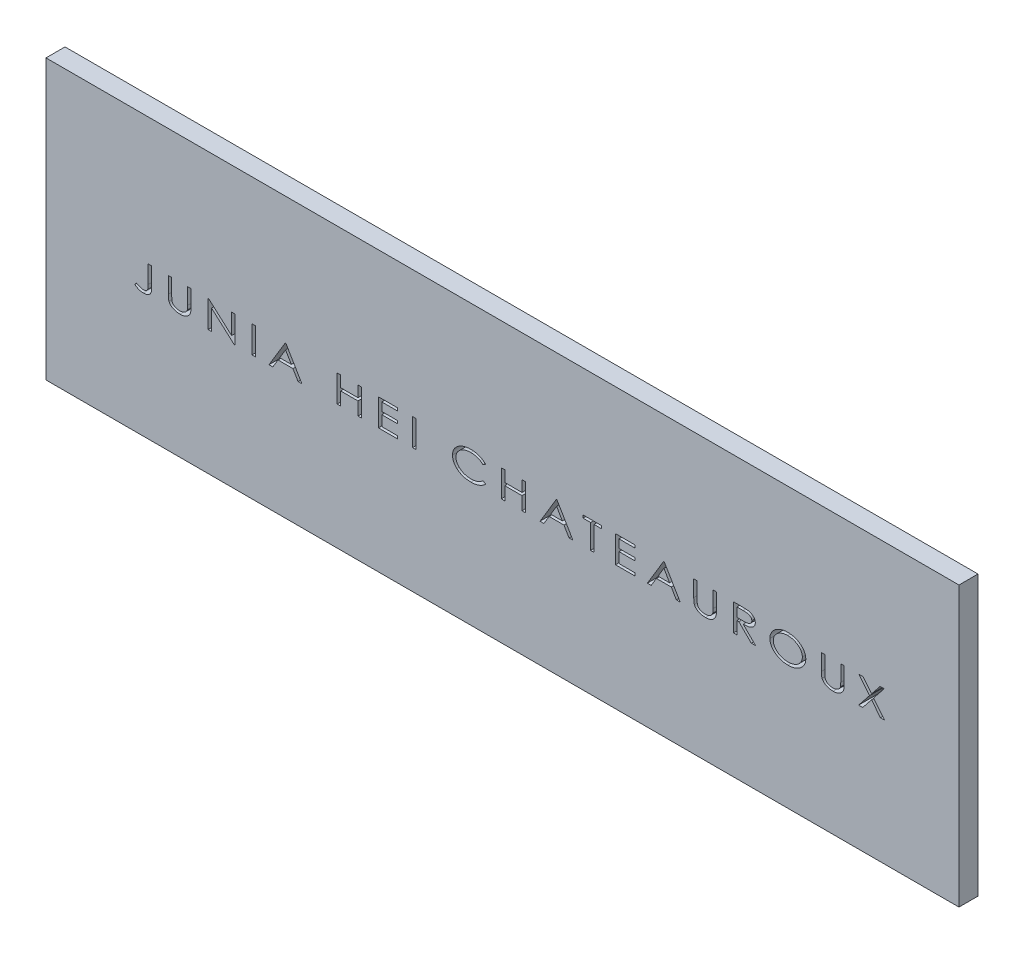
from build123d import *

# Parameters (mm, degrees)
SKETCH1_W           = 288
SKETCH1_H           = 88
BOSS_EXTRUDE2_DEPTH = 6
SKETCH4_W           = 1.089743589
SKETCH4_H           = 8.5
CUT_EXTRUDE1_DEPTH  = 6


with BuildPart() as part:
    # Sketch1 → Boss-Extrude2 (new body)
    with BuildSketch(Plane.XY):
        with Locations((144, 244)):
            Rectangle(SKETCH1_W, SKETCH1_H)
    extrude(amount=BOSS_EXTRUDE2_DEPTH)

    # Sketch4 → Cut-Extrude1 (cut)
    with BuildSketch(Plane(origin=(0, 0, 0), x_dir=(-1, 0, 0), z_dir=(0, 0, -1))):
        with BuildLine():
            Line((-32.232661343, 247.846298665), (-33.322404933, 247.846298665))
            Line((-33.322404933, 247.846298665), (-33.322404933, 242.106414851))
            add(Edge.make_bspline(
                [(-33.322404933, 242.106414851), (-33.322143071, 242.000258453), (-33.321640106, 241.79636091), (-33.306986401, 241.502834152), (-33.287138496, 241.234788221), (-33.261085681, 240.991332222), (-33.224090487, 240.773503018), (-33.177826903, 240.580349081), (-33.127097717, 240.411399805), (-33.064083482, 240.265502963), (-32.99033413, 240.137145921), (-32.907998112, 240.016825027), (-32.814973455, 239.90302313), (-32.70949607, 239.79725027), (-32.595590231, 239.695816939), (-32.468324397, 239.602514549), (-32.331291604, 239.513859194), (-32.130590183, 239.406213645), (-31.856870012, 239.292932833), (-31.498891197, 239.196026547), (-31.108504554, 239.137778787), (-30.837203035, 239.131565392), (-30.696803971, 239.128349947)],
                knots=[0, 0, 0, 0, 0.000318428, 0.000611613, 0.000881418, 0.001124735, 0.001345879, 0.001543704, 0.001720344, 0.001874391, 0.002019273, 0.002163794, 0.002311392, 0.00245949, 0.0026115, 0.002768493, 0.002932389, 0.00310076, 0.003451129, 0.003818353, 0.004210867, 0.004631857, 0.004631857, 0.004631857, 0.004631857], degree=3))
            add(Edge.make_bspline(
                [(-30.696803971, 239.128349947), (-30.587125113, 239.130903927), (-30.36814429, 239.13600311), (-30.041493838, 239.179372608), (-29.716518449, 239.244788248), (-29.390461597, 239.341799182), (-29.057450043, 239.47320037), (-28.712095096, 239.646125718), (-28.349871906, 239.859395541), (-28.108299793, 240.023678034), (-27.982661343, 240.109119178)],
                knots=[0, 0, 0, 0, 0.000328908, 0.000656686, 0.000986948, 0.001322593, 0.00167578, 0.002059569, 0.00248009, 0.002935813, 0.002935813, 0.002935813, 0.002935813], degree=3))
            Line((-27.982661343, 240.109119178), (-28.554776727, 240.762965332))
            add(Edge.make_bspline(
                [(-28.554776727, 240.762965332), (-28.69037213, 240.6913204), (-28.947444111, 240.555490541), (-29.321735951, 240.382122734), (-29.655603756, 240.23291275), (-29.871038788, 240.157764296), (-29.971443394, 240.122740973)],
                knots=[0, 0, 0, 0, 0.000459975, 0.000872056, 0.001237384, 0.001556262, 0.001556262, 0.001556262, 0.001556262], degree=3))
            add(Edge.make_bspline(
                [(-29.971443394, 240.122740973), (-30.032510773, 240.104297733), (-30.153591639, 240.067729545), (-30.336739424, 240.028434551), (-30.518598911, 240.006034686), (-30.638854315, 240.002097734), (-30.698506695, 240.000144819)],
                knots=[0, 0, 0, 0, 0.00019132, 0.000379338, 0.000561179, 0.000740168, 0.000740168, 0.000740168, 0.000740168], degree=3))
            add(Edge.make_bspline(
                [(-30.698506695, 240.000144819), (-30.774766252, 240.002627901), (-30.925008446, 240.007519927), (-31.143945233, 240.050238862), (-31.353156648, 240.115973541), (-31.546938816, 240.211939268), (-31.724018445, 240.326432864), (-31.872352033, 240.465289104), (-31.994165309, 240.620059308), (-32.071259249, 240.767112622), (-32.119112554, 240.901480205), (-32.148109188, 241.024471556), (-32.175515914, 241.16752242), (-32.197682752, 241.331748736), (-32.211536674, 241.517136026), (-32.223346636, 241.723194328), (-32.232774314, 241.95024878), (-32.232700144, 242.108674348), (-32.232661343, 242.191551069)],
                knots=[0, 0, 0, 0, 0.000228571, 0.000450318, 0.000666785, 0.000884581, 0.001097094, 0.00129709, 0.001491231, 0.001685446, 0.00179208, 0.001918449, 0.00206405, 0.002229003, 0.002415232, 0.002621606, 0.002848228, 0.003096832, 0.003096832, 0.003096832, 0.003096832], degree=3))
            Line((-32.232661343, 242.191551069), (-32.232661343, 247.846298665))
        make_face()
        with BuildLine():
            Line((-38.574969035, 247.846298665), (-39.664712625, 247.846298665))
            Line((-39.664712625, 247.846298665), (-39.664712625, 242.753450107))
            add(Edge.make_bspline(
                [(-39.664712625, 242.753450107), (-39.664341426, 242.681364336), (-39.663636974, 242.544561694), (-39.668342681, 242.349910297), (-39.670554593, 242.176748616), (-39.676805088, 242.024702092), (-39.679988742, 241.893966708), (-39.689905194, 241.784582209), (-39.69673009, 241.696300344), (-39.705297023, 241.644941394), (-39.708983458, 241.622841133)],
                knots=[0, 0, 0, 0, 0.000216246, 0.000410386, 0.000584098, 0.000735726, 0.000866935, 0.000976242, 0.001065192, 0.001132379, 0.001132379, 0.001132379, 0.001132379], degree=3))
            add(Edge.make_bspline(
                [(-39.708983458, 241.622841133), (-39.725140639, 241.542869518), (-39.756744487, 241.386443043), (-39.837031437, 241.165132359), (-39.946076341, 240.964746635), (-40.082046954, 240.782294765), (-40.254653261, 240.618816089), (-40.463726682, 240.471376447), (-40.712740638, 240.338912931), (-40.99310461, 240.220937502), (-41.294683106, 240.124164303), (-41.60318656, 240.052229319), (-41.912708888, 240.007746719), (-42.119331158, 240.002671619), (-42.222204612, 240.000144819)],
                knots=[0, 0, 0, 0, 0.000244529, 0.000478305, 0.000703071, 0.00092681, 0.001158029, 0.001413171, 0.001692023, 0.002002578, 0.002324586, 0.002640968, 0.002952087, 0.003260581, 0.003260581, 0.003260581, 0.003260581], degree=3))
            add(Edge.make_bspline(
                [(-42.222204612, 240.000144819), (-42.310820451, 240.002775051), (-42.48749071, 240.00801885), (-42.749446337, 240.039693565), (-43.005072235, 240.098031044), (-43.253998306, 240.172120623), (-43.48854256, 240.271293439), (-43.707413867, 240.385036149), (-43.904802591, 240.517836032), (-44.082029738, 240.667153536), (-44.239000651, 240.832958871), (-44.370670285, 241.017904454), (-44.484880941, 241.217247749), (-44.539245085, 241.36088626), (-44.566856054, 241.433838729)],
                knots=[0, 0, 0, 0, 0.000265892, 0.0005301, 0.000789954, 0.00105172, 0.001308176, 0.00155267, 0.001790686, 0.002020257, 0.002246726, 0.002473566, 0.002699977, 0.002933647, 0.002933647, 0.002933647, 0.002933647], degree=3))
            add(Edge.make_bspline(
                [(-44.566856054, 241.433838729), (-44.575907062, 241.463788463), (-44.596011534, 241.530314051), (-44.616097029, 241.643510477), (-44.637301645, 241.776698538), (-44.651527084, 241.931425699), (-44.663435219, 242.106847357), (-44.671555708, 242.303869255), (-44.676676999, 242.52185168), (-44.677239388, 242.673986269), (-44.677533138, 242.753450107)],
                knots=[0, 0, 0, 0, 9.3789e-05, 0.000208328, 0.000344386, 0.000498396, 0.000674181, 0.00087188, 0.001089889, 0.001328276, 0.001328276, 0.001328276, 0.001328276], degree=3))
            Line((-44.677533138, 242.753450107), (-44.677533138, 247.846298665))
            Line((-44.677533138, 247.846298665), (-45.767276727, 247.846298665))
            Line((-45.767276727, 247.846298665), (-45.767276727, 242.712584723))
            add(Edge.make_bspline(
                [(-45.767276727, 242.712584723), (-45.766036417, 242.620059559), (-45.763615667, 242.439475578), (-45.752312855, 242.174747413), (-45.730895399, 241.923516219), (-45.697395534, 241.686378805), (-45.659806597, 241.462578086), (-45.609640504, 241.252517924), (-45.552517847, 241.0555944), (-45.486175329, 240.87043853), (-45.404935418, 240.695934361), (-45.307432065, 240.528030422), (-45.191336391, 240.366408633), (-45.05672218, 240.210527303), (-44.906272312, 240.059180382), (-44.7351479, 239.915844299), (-44.548530738, 239.776512243), (-44.345100216, 239.643805081), (-44.126552455, 239.523721083), (-43.896022232, 239.41807872), (-43.655113503, 239.327087461), (-43.402285012, 239.253930948), (-43.137484481, 239.198374856), (-42.861783186, 239.157347831), (-42.575088361, 239.133539049), (-42.380601358, 239.130098023), (-42.281799965, 239.128349947)],
                knots=[0, 0, 0, 0, 0.000277591, 0.000541782, 0.000794756, 0.001033635, 0.001260104, 0.001475282, 0.001681107, 0.001875023, 0.002064707, 0.002257747, 0.002456674, 0.002660753, 0.002875066, 0.003096139, 0.003329753, 0.003573451, 0.003824174, 0.004077125, 0.00433361, 0.004596034, 0.004865871, 0.005144723, 0.005431772, 0.005728169, 0.005728169, 0.005728169, 0.005728169], degree=3))
            add(Edge.make_bspline(
                [(-42.281799965, 239.128349947), (-42.17393248, 239.130251199), (-41.9625119, 239.13397766), (-41.650838381, 239.155417183), (-41.351590038, 239.195626009), (-41.062766485, 239.24673485), (-40.786990542, 239.317926355), (-40.521635946, 239.399963483), (-40.269830552, 239.501612107), (-40.029747335, 239.614653632), (-39.806019838, 239.74158267), (-39.600592393, 239.880018694), (-39.413963403, 240.028235918), (-39.247125284, 240.187172125), (-39.096613748, 240.354052315), (-38.969973631, 240.534137748), (-38.858246231, 240.721498131), (-38.802196873, 240.854736549), (-38.774187785, 240.921318697)],
                knots=[0, 0, 0, 0, 0.00032363, 0.000634315, 0.000936543, 0.001229104, 0.001513643, 0.001790439, 0.002061728, 0.002327539, 0.002586045, 0.002832564, 0.003070031, 0.003300075, 0.00352321, 0.003742921, 0.003959616, 0.004176069, 0.004176069, 0.004176069, 0.004176069], degree=3))
            add(Edge.make_bspline(
                [(-38.774187785, 240.921318697), (-38.758144392, 240.966500865), (-38.723482692, 241.064116793), (-38.683813293, 241.2266162), (-38.650892796, 241.413887854), (-38.621654122, 241.625679804), (-38.600304613, 241.862050394), (-38.585147802, 242.12326788), (-38.57721097, 242.409450728), (-38.575737246, 242.608714242), (-38.574969035, 242.712584723)],
                knots=[0, 0, 0, 0, 0.000143767, 0.000310608, 0.000500978, 0.000714091, 0.000951802, 0.00121277, 0.001498954, 0.001810571, 0.001810571, 0.001810571, 0.001810571], degree=3))
            Line((-38.574969035, 242.712584723), (-38.574969035, 247.846298665))
        make_face()
        Polygon((-51.128815189, 239.346298665), (-51.128815189, 247.846298665), (-51.358682977, 247.846298665), (-58.539071599, 241.416811486), (-58.539071599, 247.846298665), (-59.628815189, 247.846298665), (-59.628815189, 239.346298665), (-59.380217433, 239.346298665), (-52.218558779, 245.760461325), (-52.218558779, 239.346298665), align=None)
        with Locations((-65.535225446, 243.596298665)):
            Rectangle(SKETCH4_W, SKETCH4_H)
        Polygon((-75.691635702, 247.846298665), (-80.704456215, 239.346298665), (-79.504035542, 239.346298665), (-77.896663747, 242.070657639), (-73.200549965, 242.070657639), (-71.557420958, 239.346298665), (-70.351892112, 239.346298665), (-75.473686984, 247.846298665), align=None)
        Polygon((-75.574147721, 246.010761806), (-73.724989067, 242.942452511), (-77.384143715, 242.942452511), align=None, mode=Mode.SUBTRACT)
        Polygon((-91.863430574, 247.846298665), (-92.953174163, 247.846298665), (-92.953174163, 244.359119178), (-98.401892112, 244.359119178), (-98.401892112, 247.846298665), (-99.491635702, 247.846298665), (-99.491635702, 239.346298665), (-98.401892112, 239.346298665), (-98.401892112, 243.487324306), (-92.953174163, 243.487324306), (-92.953174163, 239.346298665), (-91.863430574, 239.346298665), align=None)
        Polygon((-104.853174163, 247.846298665), (-110.955738266, 247.846298665), (-110.955738266, 246.974503793), (-105.942917753, 246.974503793), (-105.942917753, 244.359119178), (-110.955738266, 244.359119178), (-110.955738266, 243.487324306), (-105.942917753, 243.487324306), (-105.942917753, 240.218093537), (-110.955738266, 240.218093537), (-110.955738266, 239.346298665), (-104.853174163, 239.346298665), align=None)
        with Locations((-116.208302369, 243.596298665)):
            Rectangle(SKETCH4_W, SKETCH4_H)
        with BuildLine():
            Line((-138.700610061, 246.286603152), (-137.849247881, 245.775785845))
            add(Edge.make_bspline(
                [(-137.849247881, 245.775785845), (-137.789634588, 245.832575671), (-137.670817467, 245.945765255), (-137.482568125, 246.104992598), (-137.28485207, 246.25272136), (-137.079033019, 246.391084977), (-136.863323801, 246.51749672), (-136.638917839, 246.63245447), (-136.406332145, 246.739069316), (-136.164979811, 246.833516667), (-135.916913677, 246.918814688), (-135.662388048, 246.992439306), (-135.401825866, 247.052832938), (-135.135113146, 247.105064002), (-134.862133655, 247.142915432), (-134.58338869, 247.172602839), (-134.298723518, 247.189911217), (-134.106682683, 247.191599215), (-134.009604452, 247.192452511)],
                knots=[0, 0, 0, 0, 0.000246965, 0.000492235, 0.00073913, 0.000987062, 0.001235869, 0.0014887, 0.001743198, 0.002003108, 0.00226588, 0.002529939, 0.002797571, 0.003068063, 0.003344985, 0.003624034, 0.003908898, 0.004200109, 0.004200109, 0.004200109, 0.004200109], degree=3))
            add(Edge.make_bspline(
                [(-134.009604452, 247.192452511), (-133.903414396, 247.191491937), (-133.693025909, 247.189588805), (-133.38062486, 247.163783789), (-133.073646658, 247.127246445), (-132.772321743, 247.074596781), (-132.477662072, 247.00581591), (-132.188273033, 246.924946215), (-131.906026376, 246.824812193), (-131.629607573, 246.714197003), (-131.365053588, 246.588268152), (-131.113960107, 246.451620404), (-130.877225829, 246.306127148), (-130.656781679, 246.148758456), (-130.451941137, 245.981642344), (-130.261699967, 245.804298638), (-130.088693639, 245.614927337), (-129.929697123, 245.417614226), (-129.788151558, 245.211744738), (-129.665782973, 244.99853648), (-129.559940064, 244.779637774), (-129.477943875, 244.552439541), (-129.410708182, 244.320599417), (-129.362328112, 244.082120444), (-129.33556266, 243.83699874), (-129.3310758, 243.671279309), (-129.328815189, 243.587785043)],
                knots=[0, 0, 0, 0, 0.000318482, 0.000630991, 0.000939762, 0.001245732, 0.001548075, 0.001847217, 0.002146625, 0.002446058, 0.002740053, 0.003025019, 0.003303335, 0.003573124, 0.003836931, 0.00409593, 0.004352613, 0.004605769, 0.004855612, 0.005101235, 0.005342668, 0.005584011, 0.005824915, 0.006066348, 0.006313049, 0.006563558, 0.006563558, 0.006563558, 0.006563558], degree=3))
            add(Edge.make_bspline(
                [(-129.328815189, 243.587785043), (-129.332447006, 243.462069773), (-129.339594033, 243.214675538), (-129.405060515, 242.85211282), (-129.510130011, 242.505669757), (-129.66109707, 242.176117433), (-129.850427085, 241.860814256), (-130.084982855, 241.563009435), (-130.360628552, 241.281705012), (-130.674824244, 241.019500475), (-131.020493341, 240.781257286), (-131.390613207, 240.570362961), (-131.785312671, 240.395006444), (-132.200580575, 240.250696371), (-132.637854865, 240.137392334), (-133.096988402, 240.059218724), (-133.578200193, 240.007495619), (-133.906733814, 240.002627756), (-134.074307977, 240.000144819)],
                knots=[0, 0, 0, 0, 0.000376856, 0.000741613, 0.0011014, 0.00146032, 0.001826215, 0.002202251, 0.002594788, 0.003005741, 0.003427992, 0.003852712, 0.004281815, 0.004721768, 0.00517027, 0.005635242, 0.006117942, 0.00662048, 0.00662048, 0.00662048, 0.00662048], degree=3))
            add(Edge.make_bspline(
                [(-134.074307977, 240.000144819), (-134.167422638, 240.000922451), (-134.3515429, 240.002460101), (-134.625248856, 240.020914808), (-134.893032683, 240.046709729), (-135.155240592, 240.087202386), (-135.411831688, 240.135349623), (-135.662145847, 240.197337011), (-135.907239524, 240.268808082), (-136.146270875, 240.35230494), (-136.380355356, 240.445413487), (-136.606973494, 240.552054989), (-136.829134371, 240.667484202), (-137.044762175, 240.795338858), (-137.255350348, 240.933526551), (-137.459080184, 241.08404235), (-137.65943464, 241.243104071), (-137.785770841, 241.35872053), (-137.849247881, 241.416811486)],
                knots=[0, 0, 0, 0, 0.000279294, 0.000552261, 0.000822667, 0.001086111, 0.001347921, 0.001605619, 0.001859393, 0.002113561, 0.002364931, 0.002614791, 0.002864599, 0.003115737, 0.003366507, 0.003619887, 0.003875437, 0.0041335, 0.0041335, 0.0041335, 0.0041335], degree=3))
            Line((-137.849247881, 241.416811486), (-138.700610061, 240.911102351))
            add(Edge.make_bspline(
                [(-138.700610061, 240.911102351), (-138.632748743, 240.841582184), (-138.496352736, 240.701852019), (-138.276814147, 240.507482761), (-138.045942799, 240.323765531), (-137.801334354, 240.153663156), (-137.545371252, 239.993911409), (-137.276441254, 239.846749606), (-136.995396403, 239.712638993), (-136.70286575, 239.590159545), (-136.399663253, 239.480667677), (-136.086566877, 239.388107564), (-135.765134158, 239.307464551), (-135.435087405, 239.241078489), (-135.095833446, 239.1899316), (-134.748019913, 239.155091643), (-134.391904676, 239.131667758), (-134.15153639, 239.129463922), (-134.030037144, 239.128349947)],
                knots=[0, 0, 0, 0, 0.00029137, 0.000585631, 0.000878945, 0.001176064, 0.001478924, 0.001783731, 0.002095222, 0.002412715, 0.002734796, 0.003061794, 0.003391758, 0.003728696, 0.004071367, 0.004420558, 0.004777115, 0.005141562, 0.005141562, 0.005141562, 0.005141562], degree=3))
            add(Edge.make_bspline(
                [(-134.030037144, 239.128349947), (-133.914786521, 239.128978955), (-133.686962911, 239.130222357), (-133.349726406, 239.150729584), (-133.021287457, 239.178270413), (-132.702303042, 239.220256625), (-132.392194738, 239.269591466), (-132.092193404, 239.335814733), (-131.80088198, 239.409588074), (-131.519161931, 239.496987234), (-131.24677047, 239.595313454), (-130.983691201, 239.706325976), (-130.730155934, 239.82941877), (-130.484400089, 239.961476759), (-130.248884242, 240.10707313), (-130.022328645, 240.263439136), (-129.80507951, 240.432256071), (-129.668142056, 240.553896894), (-129.599548362, 240.614828312)],
                knots=[0, 0, 0, 0, 0.000345691, 0.00068335, 0.001013248, 0.001334269, 0.001648347, 0.001954932, 0.002255582, 0.002549646, 0.00283943, 0.00312405, 0.003405823, 0.003684675, 0.003960648, 0.004236011, 0.004510197, 0.004785386, 0.004785386, 0.004785386, 0.004785386], degree=3))
            add(Edge.make_bspline(
                [(-129.599548362, 240.614828312), (-129.491260511, 240.720072966), (-129.278204019, 240.927141964), (-129.000586567, 241.267548316), (-128.764627852, 241.623712858), (-128.573787468, 241.997170029), (-128.421292171, 242.385571986), (-128.317640083, 242.791767002), (-128.249312133, 243.213141322), (-128.242518119, 243.500104693), (-128.239071599, 243.645677671)],
                knots=[0, 0, 0, 0, 0.000452713, 0.000890714, 0.001314802, 0.001732119, 0.002146665, 0.002563791, 0.002987629, 0.003424005, 0.003424005, 0.003424005, 0.003424005], degree=3))
            add(Edge.make_bspline(
                [(-128.239071599, 243.645677671), (-128.240522649, 243.722899737), (-128.243396969, 243.875865534), (-128.262017214, 244.102840055), (-128.29507934, 244.324948953), (-128.338634881, 244.542987293), (-128.396652119, 244.756325364), (-128.468697466, 244.964115228), (-128.552158964, 245.167978666), (-128.649560862, 245.366623788), (-128.758267952, 245.561700079), (-128.882112168, 245.750541923), (-129.016013753, 245.936863356), (-129.164833947, 246.116825735), (-129.32500285, 246.293077806), (-129.499692621, 246.463374431), (-129.686592276, 246.62987695), (-129.952759444, 246.84588494), (-130.306856263, 247.09528272), (-130.759946567, 247.355402505), (-131.23957846, 247.573056022), (-131.743563813, 247.754981519), (-132.274803384, 247.894125535), (-132.831825646, 247.99165036), (-133.414558099, 248.052810374), (-133.811934305, 248.060383082), (-134.014712625, 248.064247383)],
                knots=[0, 0, 0, 0, 0.000231671, 0.000458906, 0.000682612, 0.000905012, 0.001125585, 0.001345283, 0.001564412, 0.001786015, 0.002008623, 0.002233904, 0.002463122, 0.002696619, 0.002934056, 0.003177277, 0.003428127, 0.003684748, 0.004205336, 0.004725515, 0.005249733, 0.005783479, 0.006331124, 0.006894929, 0.007478608, 0.008086824, 0.008086824, 0.008086824, 0.008086824], degree=3))
            add(Edge.make_bspline(
                [(-134.014712625, 248.064247383), (-134.138477353, 248.063094948), (-134.382806222, 248.06081988), (-134.744716996, 248.038054098), (-135.096888168, 248.000684136), (-135.439955123, 247.949302001), (-135.774567745, 247.885747018), (-136.099233787, 247.803267136), (-136.415111956, 247.707769299), (-136.721204371, 247.599567662), (-137.015726787, 247.476376782), (-137.298317278, 247.343034695), (-137.565774005, 247.19546741), (-137.821274765, 247.039579022), (-138.060661015, 246.867788628), (-138.290227119, 246.688551073), (-138.503080814, 246.493865746), (-138.634973198, 246.355474302), (-138.700610061, 246.286603152)],
                knots=[0, 0, 0, 0, 0.000371256, 0.000732912, 0.001087361, 0.0014334, 0.001773348, 0.002108681, 0.0024378, 0.002763088, 0.003082152, 0.00339518, 0.003699987, 0.003998158, 0.004292493, 0.004583415, 0.004871478, 0.00515685, 0.00515685, 0.00515685, 0.00515685], degree=3))
        make_face()
        Polygon((-143.626251086, 247.846298665), (-144.715994676, 247.846298665), (-144.715994676, 244.359119178), (-150.164712625, 244.359119178), (-150.164712625, 247.846298665), (-151.254456215, 247.846298665), (-151.254456215, 239.346298665), (-150.164712625, 239.346298665), (-150.164712625, 243.487324306), (-144.715994676, 243.487324306), (-144.715994676, 239.346298665), (-143.626251086, 239.346298665), align=None)
        Polygon((-161.192917753, 247.846298665), (-166.205738266, 239.346298665), (-165.005317593, 239.346298665), (-163.397945798, 242.070657639), (-158.701832016, 242.070657639), (-157.05870301, 239.346298665), (-155.853174163, 239.346298665), (-160.974969035, 247.846298665), align=None)
        Polygon((-161.075429772, 246.010761806), (-159.226271118, 242.942452511), (-162.885425766, 242.942452511), align=None, mode=Mode.SUBTRACT)
        Polygon((-169.387789548, 246.974503793), (-169.387789548, 247.846298665), (-175.272404933, 247.846298665), (-175.272404933, 246.974503793), (-172.874969035, 246.974503793), (-172.874969035, 239.346298665), (-171.785225445, 239.346298665), (-171.785225445, 246.974503793), align=None)
        Polygon((-179.653174163, 247.846298665), (-185.755738266, 247.846298665), (-185.755738266, 246.974503793), (-180.742917753, 246.974503793), (-180.742917753, 244.359119178), (-185.755738266, 244.359119178), (-185.755738266, 243.487324306), (-180.742917753, 243.487324306), (-180.742917753, 240.218093537), (-185.755738266, 240.218093537), (-185.755738266, 239.346298665), (-179.653174163, 239.346298665), align=None)
        Polygon((-195.040353651, 247.846298665), (-200.053174163, 239.346298665), (-198.85275349, 239.346298665), (-197.245381695, 242.070657639), (-192.549267913, 242.070657639), (-190.906138907, 239.346298665), (-189.700610061, 239.346298665), (-194.822404933, 247.846298665), align=None)
        Polygon((-194.92286567, 246.010761806), (-193.073707016, 242.942452511), (-196.732861663, 242.942452511), align=None, mode=Mode.SUBTRACT)
        with BuildLine():
            Line((-204.324969035, 247.846298665), (-205.414712625, 247.846298665))
            Line((-205.414712625, 247.846298665), (-205.414712625, 242.753450107))
            add(Edge.make_bspline(
                [(-205.414712625, 242.753450107), (-205.414341426, 242.681364336), (-205.413636974, 242.544561694), (-205.418342681, 242.349910297), (-205.420554593, 242.176748616), (-205.426805088, 242.024702092), (-205.429988742, 241.893966708), (-205.439905194, 241.784582209), (-205.44673009, 241.696300344), (-205.455297023, 241.644941394), (-205.458983458, 241.622841133)],
                knots=[0, 0, 0, 0, 0.000216246, 0.000410386, 0.000584098, 0.000735726, 0.000866935, 0.000976242, 0.001065192, 0.001132379, 0.001132379, 0.001132379, 0.001132379], degree=3))
            add(Edge.make_bspline(
                [(-205.458983458, 241.622841133), (-205.475140639, 241.542869518), (-205.506744487, 241.386443043), (-205.587031437, 241.165132359), (-205.696076341, 240.964746635), (-205.832046954, 240.782294765), (-206.004653261, 240.618816089), (-206.213726682, 240.471376447), (-206.462740638, 240.338912931), (-206.74310461, 240.220937502), (-207.044683106, 240.124164303), (-207.35318656, 240.052229319), (-207.662708888, 240.007746719), (-207.869331158, 240.002671619), (-207.972204612, 240.000144819)],
                knots=[0, 0, 0, 0, 0.000244529, 0.000478305, 0.000703071, 0.00092681, 0.001158029, 0.001413171, 0.001692023, 0.002002578, 0.002324586, 0.002640968, 0.002952087, 0.003260581, 0.003260581, 0.003260581, 0.003260581], degree=3))
            add(Edge.make_bspline(
                [(-207.972204612, 240.000144819), (-208.060820451, 240.002775051), (-208.23749071, 240.00801885), (-208.499446337, 240.039693565), (-208.755072235, 240.098031044), (-209.003998306, 240.172120623), (-209.23854256, 240.271293439), (-209.457413867, 240.385036149), (-209.654802591, 240.517836032), (-209.832029738, 240.667153536), (-209.989000651, 240.832958871), (-210.120670285, 241.017904454), (-210.234880941, 241.217247749), (-210.289245085, 241.36088626), (-210.316856054, 241.433838729)],
                knots=[0, 0, 0, 0, 0.000265892, 0.0005301, 0.000789954, 0.00105172, 0.001308176, 0.00155267, 0.001790686, 0.002020257, 0.002246726, 0.002473566, 0.002699977, 0.002933647, 0.002933647, 0.002933647, 0.002933647], degree=3))
            add(Edge.make_bspline(
                [(-210.316856054, 241.433838729), (-210.325907062, 241.463788463), (-210.346011534, 241.530314051), (-210.366097029, 241.643510477), (-210.387301645, 241.776698538), (-210.401527084, 241.931425699), (-210.413435219, 242.106847357), (-210.421555708, 242.303869255), (-210.426676999, 242.52185168), (-210.427239388, 242.673986269), (-210.427533138, 242.753450107)],
                knots=[0, 0, 0, 0, 9.3789e-05, 0.000208328, 0.000344386, 0.000498396, 0.000674181, 0.00087188, 0.001089889, 0.001328276, 0.001328276, 0.001328276, 0.001328276], degree=3))
            Line((-210.427533138, 242.753450107), (-210.427533138, 247.846298665))
            Line((-210.427533138, 247.846298665), (-211.517276727, 247.846298665))
            Line((-211.517276727, 247.846298665), (-211.517276727, 242.712584723))
            add(Edge.make_bspline(
                [(-211.517276727, 242.712584723), (-211.516036417, 242.620059559), (-211.513615667, 242.439475578), (-211.502312855, 242.174747413), (-211.480895399, 241.923516219), (-211.447395534, 241.686378805), (-211.409806597, 241.462578086), (-211.359640504, 241.252517924), (-211.302517847, 241.0555944), (-211.236175329, 240.87043853), (-211.154935418, 240.695934361), (-211.057432065, 240.528030422), (-210.941336391, 240.366408633), (-210.80672218, 240.210527303), (-210.656272312, 240.059180382), (-210.4851479, 239.915844299), (-210.298530738, 239.776512243), (-210.095100216, 239.643805081), (-209.876552455, 239.523721083), (-209.646022232, 239.41807872), (-209.405113503, 239.327087461), (-209.152285012, 239.253930948), (-208.887484481, 239.198374856), (-208.611783186, 239.157347831), (-208.325088361, 239.133539049), (-208.130601358, 239.130098023), (-208.031799965, 239.128349947)],
                knots=[0, 0, 0, 0, 0.000277591, 0.000541782, 0.000794756, 0.001033635, 0.001260104, 0.001475282, 0.001681107, 0.001875023, 0.002064707, 0.002257747, 0.002456674, 0.002660753, 0.002875066, 0.003096139, 0.003329753, 0.003573451, 0.003824174, 0.004077125, 0.00433361, 0.004596034, 0.004865871, 0.005144723, 0.005431772, 0.005728169, 0.005728169, 0.005728169, 0.005728169], degree=3))
            add(Edge.make_bspline(
                [(-208.031799965, 239.128349947), (-207.92393248, 239.130251199), (-207.7125119, 239.13397766), (-207.400838381, 239.155417183), (-207.101590038, 239.195626009), (-206.812766485, 239.24673485), (-206.536990542, 239.317926355), (-206.271635946, 239.399963483), (-206.019830552, 239.501612107), (-205.779747335, 239.614653632), (-205.556019838, 239.74158267), (-205.350592393, 239.880018694), (-205.163963403, 240.028235918), (-204.997125284, 240.187172125), (-204.846613748, 240.354052315), (-204.719973631, 240.534137748), (-204.608246231, 240.721498131), (-204.552196873, 240.854736549), (-204.524187785, 240.921318697)],
                knots=[0, 0, 0, 0, 0.00032363, 0.000634315, 0.000936543, 0.001229104, 0.001513643, 0.001790439, 0.002061728, 0.002327539, 0.002586045, 0.002832564, 0.003070031, 0.003300075, 0.00352321, 0.003742921, 0.003959616, 0.004176069, 0.004176069, 0.004176069, 0.004176069], degree=3))
            add(Edge.make_bspline(
                [(-204.524187785, 240.921318697), (-204.508144392, 240.966500865), (-204.473482692, 241.064116793), (-204.433813293, 241.2266162), (-204.400892796, 241.413887854), (-204.371654122, 241.625679804), (-204.350304613, 241.862050394), (-204.335147802, 242.12326788), (-204.32721097, 242.409450728), (-204.325737246, 242.608714242), (-204.324969035, 242.712584723)],
                knots=[0, 0, 0, 0, 0.000143767, 0.000310608, 0.000500978, 0.000714091, 0.000951802, 0.00121277, 0.001498954, 0.001810571, 0.001810571, 0.001810571, 0.001810571], degree=3))
            Line((-204.324969035, 242.712584723), (-204.324969035, 247.846298665))
        make_face()
        with BuildLine():
            Line((-216.878815189, 247.846298665), (-219.065113266, 247.846298665))
            add(Edge.make_bspline(
                [(-219.065113266, 247.846298665), (-219.211546993, 247.845925285), (-219.491937666, 247.845210339), (-219.893844643, 247.841123916), (-220.258745713, 247.829566112), (-220.586966045, 247.819592183), (-220.878056847, 247.801378628), (-221.132575224, 247.78408232), (-221.350201714, 247.761122889), (-221.482481318, 247.740075458), (-221.542577208, 247.730513409)],
                knots=[0, 0, 0, 0, 0.000439306, 0.000841182, 0.001205708, 0.00153455, 0.001826213, 0.002080609, 0.002299858, 0.002482391, 0.002482391, 0.002482391, 0.002482391], degree=3))
            add(Edge.make_bspline(
                [(-221.542577208, 247.730513409), (-221.622283562, 247.715144536), (-221.779489901, 247.68483222), (-222.006872978, 247.621418768), (-222.222889936, 247.546079994), (-222.428134359, 247.45942016), (-222.621874112, 247.359490963), (-222.803399152, 247.245823505), (-222.97469795, 247.121982741), (-223.131689791, 246.984368113), (-223.275800246, 246.837975634), (-223.402109389, 246.682548137), (-223.506307107, 246.516429664), (-223.594825973, 246.344582845), (-223.65980224, 246.162588861), (-223.711566012, 245.9740841), (-223.737343169, 245.77592777), (-223.741894744, 245.641327462), (-223.744199804, 245.573161646)],
                knots=[0, 0, 0, 0, 0.000243442, 0.000480145, 0.000707393, 0.000929408, 0.001147974, 0.00136059, 0.001571405, 0.0017814, 0.001986096, 0.002187132, 0.002380802, 0.002573458, 0.002765776, 0.002959475, 0.003158861, 0.003363443, 0.003363443, 0.003363443, 0.003363443], degree=3))
            add(Edge.make_bspline(
                [(-223.744199804, 245.573161646), (-223.742971873, 245.51576517), (-223.740544526, 245.402305054), (-223.718795733, 245.235075385), (-223.687564569, 245.072991114), (-223.640517095, 244.916530321), (-223.581627623, 244.765148233), (-223.507093776, 244.61919499), (-223.420630127, 244.478527039), (-223.321681018, 244.342912658), (-223.208576337, 244.216148589), (-223.08629586, 244.094209217), (-222.951128763, 243.982445909), (-222.805677402, 243.877060889), (-222.646710041, 243.783150836), (-222.478033191, 243.693553977), (-222.297310875, 243.614338385), (-222.104942647, 243.541651552), (-221.897062103, 243.47924478), (-221.671908343, 243.421941572), (-221.426913691, 243.378087419), (-221.164170664, 243.338127388), (-220.882930764, 243.308075567), (-220.582521444, 243.28617057), (-220.263388384, 243.272510813), (-220.044193478, 243.270438288), (-219.931799965, 243.269375588)],
                knots=[0, 0, 0, 0, 0.00017211, 0.000340223, 0.000505186, 0.00066681, 0.000829649, 0.000991847, 0.00115772, 0.001324596, 0.001494707, 0.001666884, 0.001842165, 0.00202031, 0.002205155, 0.002395564, 0.002592999, 0.002796672, 0.003012119, 0.003243796, 0.003493261, 0.003758389, 0.004041005, 0.004341501, 0.004661903, 0.004999081, 0.004999081, 0.004999081, 0.004999081], degree=3))
            Line((-219.931799965, 243.269375588), (-223.853174163, 239.346298665))
            Line((-223.853174163, 239.346298665), (-222.467156535, 239.346298665))
            Line((-222.467156535, 239.346298665), (-218.545782336, 243.269375588))
            Line((-218.545782336, 243.269375588), (-217.968558779, 243.269375588))
            Line((-217.968558779, 243.269375588), (-217.968558779, 239.346298665))
            Line((-217.968558779, 239.346298665), (-216.878815189, 239.346298665))
            Line((-216.878815189, 239.346298665), (-216.878815189, 247.846298665))
        make_face()
        with BuildLine():
            Line((-217.968558779, 246.974503793), (-217.968558779, 244.14117046))
            Line((-217.968558779, 244.14117046), (-219.880718234, 244.129251389))
            add(Edge.make_bspline(
                [(-219.880718234, 244.129251389), (-219.970406195, 244.129210173), (-220.143584601, 244.12913059), (-220.393883121, 244.138864337), (-220.62614856, 244.149847174), (-220.840793229, 244.166876006), (-221.037376556, 244.188366985), (-221.21577238, 244.215602561), (-221.376122428, 244.247556267), (-221.563217246, 244.296013776), (-221.772250265, 244.372839246), (-221.998803855, 244.48549866), (-222.193041181, 244.627254904), (-222.357988223, 244.789152), (-222.488916578, 244.968947502), (-222.58522628, 245.161278386), (-222.643773241, 245.36486523), (-222.65088594, 245.504682161), (-222.654456215, 245.57486437)],
                knots=[0, 0, 0, 0, 0.000269036, 0.000519481, 0.000751358, 0.000966576, 0.001165329, 0.001344495, 0.001507788, 0.001655641, 0.001923895, 0.002174432, 0.002412162, 0.002642131, 0.002865214, 0.003076146, 0.003284776, 0.003495047, 0.003495047, 0.003495047, 0.003495047], degree=3))
            add(Edge.make_bspline(
                [(-222.654456215, 245.57486437), (-222.650880737, 245.643354987), (-222.643755356, 245.779846295), (-222.584988474, 245.97912081), (-222.487597472, 246.167331258), (-222.353199959, 246.340957659), (-222.193122864, 246.501741375), (-222.003063935, 246.635886534), (-221.79131744, 246.748360385), (-221.594772458, 246.818653393), (-221.419134525, 246.86304347), (-221.265764137, 246.893629164), (-221.092375077, 246.918597707), (-220.898611842, 246.938435813), (-220.684620401, 246.955703), (-220.450101421, 246.967093187), (-220.195198078, 246.974033604), (-220.018643892, 246.974342773), (-219.926691792, 246.974503793)],
                knots=[0, 0, 0, 0, 0.000205184, 0.000408899, 0.000617558, 0.000837552, 0.001065113, 0.001295711, 0.001532592, 0.001782516, 0.001919625, 0.002075905, 0.00225145, 0.00244494, 0.002660158, 0.002895436, 0.003149233, 0.00342508, 0.00342508, 0.00342508, 0.00342508], degree=3))
            Line((-219.926691792, 246.974503793), (-217.968558779, 246.974503793))
        make_face(mode=Mode.SUBTRACT)
        with BuildLine():
            add(Edge.make_bspline(
                [(-233.939772721, 248.064247383), (-234.139124462, 248.060235184), (-234.530793725, 248.052352359), (-235.10611212, 247.992933357), (-235.655994503, 247.889345449), (-236.182845275, 247.751858245), (-236.683081703, 247.568154104), (-237.159251141, 247.346287224), (-237.610416581, 247.083419011), (-237.962903141, 246.830686728), (-238.228777462, 246.6128625), (-238.415661087, 246.444633811), (-238.590354395, 246.272631882), (-238.750513209, 246.0946743), (-238.899337556, 245.913005955), (-239.033226349, 245.72498467), (-239.157089844, 245.534440465), (-239.265716286, 245.337635407), (-239.363616931, 245.13692303), (-239.446231351, 244.930449555), (-239.518740903, 244.720577401), (-239.576651838, 244.505504832), (-239.620435619, 244.285240198), (-239.653157613, 244.060811148), (-239.671951025, 243.831596108), (-239.674808584, 243.677494789), (-239.676251086, 243.599704114)],
                knots=[0, 0, 0, 0, 0.000598005, 0.00117491, 0.001732624, 0.002275331, 0.002806456, 0.003329012, 0.003849422, 0.004370592, 0.004628289, 0.004880275, 0.005124692, 0.005363389, 0.005598205, 0.005828803, 0.006055515, 0.006279609, 0.006502744, 0.006725026, 0.006946334, 0.007168551, 0.00739262, 0.007619696, 0.007848628, 0.008082001, 0.008082001, 0.008082001, 0.008082001], degree=3))
            add(Edge.make_bspline(
                [(-239.676251086, 243.599704114), (-239.674808373, 243.52248092), (-239.671950565, 243.369512887), (-239.653162658, 243.141994581), (-239.620417721, 242.919274954), (-239.576718969, 242.700676161), (-239.518342924, 242.486903224), (-239.446801253, 242.277800285), (-239.362737044, 242.072799117), (-239.267975979, 241.871436245), (-239.158015969, 241.67509837), (-239.036167163, 241.48322492), (-238.899765658, 241.296454155), (-238.753068186, 241.113110096), (-238.590844819, 240.935338765), (-238.418717524, 240.760281184), (-238.231449076, 240.591302632), (-237.967135205, 240.371912276), (-237.616408799, 240.119199165), (-237.170686271, 239.853026925), (-236.702366903, 239.628022493), (-236.210071275, 239.445699917), (-235.697179323, 239.301805729), (-235.160271764, 239.202791151), (-234.601948442, 239.139529725), (-234.221463982, 239.132114315), (-234.028314388, 239.128349947)],
                knots=[0, 0, 0, 0, 0.000231671, 0.000458906, 0.000684297, 0.000906697, 0.00112727, 0.001348578, 0.001569283, 0.001791683, 0.002015777, 0.002243923, 0.00247314, 0.002709279, 0.002947977, 0.003194801, 0.003445524, 0.003704305, 0.004225085, 0.004740493, 0.005259891, 0.005781431, 0.006313535, 0.006855873, 0.00741772, 0.007997007, 0.007997007, 0.007997007, 0.007997007], degree=3))
            add(Edge.make_bspline(
                [(-234.028314388, 239.128349947), (-233.83289588, 239.132095665), (-233.448449985, 239.139464598), (-232.883903891, 239.202877863), (-232.342095194, 239.301851401), (-231.82371128, 239.443816518), (-231.328359637, 239.626012627), (-230.856272929, 239.849691565), (-230.408692282, 240.115478567), (-230.056140899, 240.366860004), (-229.790513579, 240.584969475), (-229.602796953, 240.75293278), (-229.430020742, 240.926790625), (-229.267937249, 241.102948791), (-229.120453475, 241.284606751), (-228.985888115, 241.470936351), (-228.862068818, 241.659829987), (-228.753901041, 241.854590551), (-228.655517582, 242.052197178), (-228.572972717, 242.255317076), (-228.500407046, 242.461762936), (-228.442760375, 242.672928609), (-228.398695587, 242.888593231), (-228.366020831, 243.107931985), (-228.347212819, 243.332046855), (-228.344358753, 243.482749792), (-228.342917753, 243.558838729)],
                knots=[0, 0, 0, 0, 0.000586093, 0.001153019, 0.001702052, 0.002236984, 0.002763313, 0.003283514, 0.00380185, 0.00432302, 0.004580717, 0.004832703, 0.005078321, 0.005315758, 0.005550573, 0.005779791, 0.006005072, 0.00622768, 0.006447753, 0.006666883, 0.006884971, 0.007103902, 0.007322965, 0.007544987, 0.007768828, 0.007997095, 0.007997095, 0.007997095, 0.007997095], degree=3))
            add(Edge.make_bspline(
                [(-228.342917753, 243.558838729), (-228.345140939, 243.659980404), (-228.349563822, 243.861195152), (-228.387230477, 244.159944592), (-228.444400486, 244.453926448), (-228.526406137, 244.742139797), (-228.632591675, 245.024497489), (-228.763002194, 245.300530669), (-228.914227485, 245.572176944), (-229.090385715, 245.835259514), (-229.284683612, 246.089613357), (-229.498671472, 246.330888662), (-229.730181267, 246.556779095), (-229.978253703, 246.768847905), (-230.242820862, 246.966650704), (-230.524491234, 247.150570278), (-230.822599871, 247.321399224), (-231.137290053, 247.474799521), (-231.462202557, 247.614923652), (-231.797279619, 247.733212106), (-232.137916349, 247.836191192), (-232.485893855, 247.919446739), (-232.840026872, 247.984292574), (-233.201033121, 248.029485516), (-233.568041187, 248.060326502), (-233.815410094, 248.062935654), (-233.939772721, 248.064247383)],
                knots=[0, 0, 0, 0, 0.000303319, 0.000603434, 0.000901969, 0.001201112, 0.001501241, 0.001805928, 0.002116189, 0.002433069, 0.002754902, 0.003075747, 0.003399646, 0.003724509, 0.004054157, 0.004389939, 0.004733134, 0.005084184, 0.005439675, 0.005794054, 0.006149594, 0.006506829, 0.006866858, 0.007229062, 0.007597988, 0.007970982, 0.007970982, 0.007970982, 0.007970982], degree=3))
        make_face()
        with BuildLine():
            add(Edge.make_bspline(
                [(-233.987449003, 247.192452511), (-233.888066325, 247.191487803), (-233.690707225, 247.189572036), (-233.396472642, 247.163598929), (-233.105941685, 247.127155244), (-232.819112973, 247.074886048), (-232.537313109, 247.003347285), (-232.258295483, 246.921125052), (-231.983362192, 246.821622571), (-231.714675433, 246.708252408), (-231.454406843, 246.583070819), (-231.20772426, 246.445295755), (-230.975388959, 246.296590995), (-230.757095124, 246.138608212), (-230.553932444, 245.96974289), (-230.365542617, 245.79004694), (-230.191855808, 245.599546774), (-230.034067887, 245.398976863), (-229.891962867, 245.191318949), (-229.769104088, 244.976038384), (-229.66457019, 244.754862466), (-229.581703624, 244.526946654), (-229.514313075, 244.294531129), (-229.466525587, 244.055956058), (-229.439281365, 243.810908155), (-229.434884285, 243.645743245), (-229.432661343, 243.562244178)],
                knots=[0, 0, 0, 0, 0.000298055, 0.000591892, 0.000885457, 0.001176344, 0.001465838, 0.001757282, 0.002048667, 0.002342455, 0.002631843, 0.002914649, 0.003189548, 0.00345895, 0.003722526, 0.003981458, 0.004239396, 0.004495219, 0.004746468, 0.004993568, 0.005238079, 0.005479422, 0.005720326, 0.005963428, 0.006208437, 0.006458946, 0.006458946, 0.006458946, 0.006458946], degree=3))
            add(Edge.make_bspline(
                [(-229.432661343, 243.562244178), (-229.436289972, 243.43935649), (-229.443445712, 243.197019121), (-229.509233223, 242.84204448), (-229.612867625, 242.501366188), (-229.761451611, 242.176062035), (-229.949623128, 241.863949716), (-230.181896814, 241.568575483), (-230.455139246, 241.287824681), (-230.766238031, 241.025707346), (-231.10590338, 240.785117074), (-231.467706932, 240.575869122), (-231.845691194, 240.397443082), (-232.241432237, 240.252838091), (-232.653417374, 240.137896626), (-233.083786432, 240.059438757), (-233.529849762, 240.007676464), (-233.833487055, 240.002678885), (-233.987449003, 240.000144819)],
                knots=[0, 0, 0, 0, 0.000368356, 0.000726406, 0.001079182, 0.001434297, 0.001796397, 0.002170044, 0.002558985, 0.002969733, 0.003388773, 0.003806107, 0.004221994, 0.004641106, 0.005068666, 0.005503478, 0.005952317, 0.006414009, 0.006414009, 0.006414009, 0.006414009], degree=3))
            add(Edge.make_bspline(
                [(-233.987449003, 240.000144819), (-234.091354469, 240.001316946), (-234.297703762, 240.003644711), (-234.604046111, 240.026441491), (-234.904716061, 240.063699214), (-235.199013802, 240.116655973), (-235.487547333, 240.183556617), (-235.770851304, 240.262252588), (-236.046782783, 240.360970422), (-236.31680777, 240.470239497), (-236.575779326, 240.594189982), (-236.822352983, 240.72879165), (-237.053700515, 240.875138539), (-237.270543571, 241.031893979), (-237.47269212, 241.199497928), (-237.659789618, 241.378209899), (-237.833025462, 241.567613659), (-237.988755112, 241.768921855), (-238.130583456, 241.976612515), (-238.250982511, 242.192866195), (-238.356884298, 242.412490915), (-238.438889193, 242.640188701), (-238.507081552, 242.871754363), (-238.551546018, 243.110293966), (-238.582668339, 243.353686382), (-238.585221679, 243.518439841), (-238.586507497, 243.601406838)],
                knots=[0, 0, 0, 0, 0.000311673, 0.000618962, 0.000920973, 0.001220237, 0.00151556, 0.001809323, 0.002101741, 0.002394223, 0.002682874, 0.002962541, 0.003236526, 0.00350355, 0.003764728, 0.00402366, 0.004279193, 0.004533965, 0.004786623, 0.005032884, 0.005275855, 0.005517197, 0.005758101, 0.005999204, 0.006244408, 0.006493151, 0.006493151, 0.006493151, 0.006493151], degree=3))
            add(Edge.make_bspline(
                [(-238.586507497, 243.601406838), (-238.585220738, 243.683806608), (-238.582665599, 243.847429272), (-238.551559288, 244.089127823), (-238.507033743, 244.325954123), (-238.439196629, 244.555376712), (-238.356820448, 244.780151767), (-238.250957242, 244.996370272), (-238.130524465, 245.209230158), (-237.988686871, 245.413483073), (-237.832560363, 245.612152438), (-237.657993877, 245.798484477), (-237.470336838, 245.977283279), (-237.265424642, 246.143007671), (-237.04674534, 246.301144434), (-236.811532014, 246.446373596), (-236.561954412, 246.583829298), (-236.297985827, 246.707769869), (-236.025168696, 246.822107791), (-235.745944979, 246.92073143), (-235.462628679, 247.003679003), (-235.176170235, 247.074858938), (-234.8848095, 247.126990381), (-234.589222324, 247.163839506), (-234.28985008, 247.189486152), (-234.088531147, 247.191460961), (-233.987449003, 247.192452511)],
                knots=[0, 0, 0, 0, 0.000247042, 0.000490555, 0.000729986, 0.000969254, 0.001207404, 0.001447301, 0.0016906, 0.001940443, 0.002192538, 0.002447969, 0.002705728, 0.002969535, 0.00323794, 0.003514809, 0.003798281, 0.004092276, 0.004389205, 0.0046854, 0.00498011, 0.005274563, 0.005570474, 0.005867418, 0.006168044, 0.006471206, 0.006471206, 0.006471206, 0.006471206], degree=3))
        make_face(mode=Mode.SUBTRACT)
        with BuildLine():
            Line((-244.601892112, 247.846298665), (-245.691635702, 247.846298665))
            Line((-245.691635702, 247.846298665), (-245.691635702, 242.753450107))
            add(Edge.make_bspline(
                [(-245.691635702, 242.753450107), (-245.691264503, 242.681364336), (-245.690560051, 242.544561694), (-245.695265758, 242.349910297), (-245.69747767, 242.176748616), (-245.703728165, 242.024702092), (-245.706911819, 241.893966708), (-245.716828271, 241.784582209), (-245.723653167, 241.696300344), (-245.7322201, 241.644941394), (-245.735906535, 241.622841133)],
                knots=[0, 0, 0, 0, 0.000216246, 0.000410386, 0.000584098, 0.000735726, 0.000866935, 0.000976242, 0.001065192, 0.001132379, 0.001132379, 0.001132379, 0.001132379], degree=3))
            add(Edge.make_bspline(
                [(-245.735906535, 241.622841133), (-245.752063716, 241.542869518), (-245.783667564, 241.386443043), (-245.863954514, 241.165132359), (-245.972999418, 240.964746635), (-246.108970031, 240.782294765), (-246.281576338, 240.618816089), (-246.490649759, 240.471376447), (-246.739663715, 240.338912931), (-247.020027686, 240.220937502), (-247.321606183, 240.124164303), (-247.630109637, 240.052229319), (-247.939631965, 240.007746719), (-248.146254235, 240.002671619), (-248.249127689, 240.000144819)],
                knots=[0, 0, 0, 0, 0.000244529, 0.000478305, 0.000703071, 0.00092681, 0.001158029, 0.001413171, 0.001692023, 0.002002578, 0.002324586, 0.002640968, 0.002952087, 0.003260581, 0.003260581, 0.003260581, 0.003260581], degree=3))
            add(Edge.make_bspline(
                [(-248.249127689, 240.000144819), (-248.337743528, 240.002775051), (-248.514413787, 240.00801885), (-248.776369414, 240.039693565), (-249.031995312, 240.098031044), (-249.280921383, 240.172120623), (-249.515465637, 240.271293439), (-249.734336944, 240.385036149), (-249.931725668, 240.517836032), (-250.108952815, 240.667153536), (-250.265923727, 240.832958871), (-250.397593362, 241.017904454), (-250.511804018, 241.217247749), (-250.566168162, 241.36088626), (-250.593779131, 241.433838729)],
                knots=[0, 0, 0, 0, 0.000265892, 0.0005301, 0.000789954, 0.00105172, 0.001308176, 0.00155267, 0.001790686, 0.002020257, 0.002246726, 0.002473566, 0.002699977, 0.002933647, 0.002933647, 0.002933647, 0.002933647], degree=3))
            add(Edge.make_bspline(
                [(-250.593779131, 241.433838729), (-250.602830139, 241.463788463), (-250.622934611, 241.530314051), (-250.643020106, 241.643510477), (-250.664224722, 241.776698538), (-250.678450161, 241.931425699), (-250.690358296, 242.106847357), (-250.698478785, 242.303869255), (-250.703600076, 242.52185168), (-250.704162465, 242.673986269), (-250.704456215, 242.753450107)],
                knots=[0, 0, 0, 0, 9.3789e-05, 0.000208328, 0.000344386, 0.000498396, 0.000674181, 0.00087188, 0.001089889, 0.001328276, 0.001328276, 0.001328276, 0.001328276], degree=3))
            Line((-250.704456215, 242.753450107), (-250.704456215, 247.846298665))
            Line((-250.704456215, 247.846298665), (-251.794199804, 247.846298665))
            Line((-251.794199804, 247.846298665), (-251.794199804, 242.712584723))
            add(Edge.make_bspline(
                [(-251.794199804, 242.712584723), (-251.792959494, 242.620059559), (-251.790538744, 242.439475578), (-251.779235932, 242.174747413), (-251.757818476, 241.923516219), (-251.724318611, 241.686378805), (-251.686729674, 241.462578086), (-251.636563581, 241.252517924), (-251.579440924, 241.0555944), (-251.513098406, 240.87043853), (-251.431858495, 240.695934361), (-251.334355142, 240.528030422), (-251.218259468, 240.366408633), (-251.083645257, 240.210527303), (-250.933195389, 240.059180382), (-250.762070977, 239.915844299), (-250.575453815, 239.776512243), (-250.372023293, 239.643805081), (-250.153475532, 239.523721083), (-249.922945309, 239.41807872), (-249.68203658, 239.327087461), (-249.429208089, 239.253930948), (-249.164407558, 239.198374856), (-248.888706263, 239.157347831), (-248.602011438, 239.133539049), (-248.407524435, 239.130098023), (-248.308723042, 239.128349947)],
                knots=[0, 0, 0, 0, 0.000277591, 0.000541782, 0.000794756, 0.001033635, 0.001260104, 0.001475282, 0.001681107, 0.001875023, 0.002064707, 0.002257747, 0.002456674, 0.002660753, 0.002875066, 0.003096139, 0.003329753, 0.003573451, 0.003824174, 0.004077125, 0.00433361, 0.004596034, 0.004865871, 0.005144723, 0.005431772, 0.005728169, 0.005728169, 0.005728169, 0.005728169], degree=3))
            add(Edge.make_bspline(
                [(-248.308723042, 239.128349947), (-248.200855557, 239.130251199), (-247.989434977, 239.13397766), (-247.677761457, 239.155417183), (-247.378513115, 239.195626009), (-247.089689562, 239.24673485), (-246.813913619, 239.317926355), (-246.548559023, 239.399963483), (-246.296753629, 239.501612107), (-246.056670411, 239.614653632), (-245.832942915, 239.74158267), (-245.62751547, 239.880018694), (-245.44088648, 240.028235918), (-245.274048361, 240.187172125), (-245.123536825, 240.354052315), (-244.996896708, 240.534137748), (-244.885169308, 240.721498131), (-244.82911995, 240.854736549), (-244.801110862, 240.921318697)],
                knots=[0, 0, 0, 0, 0.00032363, 0.000634315, 0.000936543, 0.001229104, 0.001513643, 0.001790439, 0.002061728, 0.002327539, 0.002586045, 0.002832564, 0.003070031, 0.003300075, 0.00352321, 0.003742921, 0.003959616, 0.004176069, 0.004176069, 0.004176069, 0.004176069], degree=3))
            add(Edge.make_bspline(
                [(-244.801110862, 240.921318697), (-244.785067469, 240.966500865), (-244.750405769, 241.064116793), (-244.71073637, 241.2266162), (-244.677815873, 241.413887854), (-244.648577199, 241.625679804), (-244.62722769, 241.862050394), (-244.612070879, 242.12326788), (-244.604134047, 242.409450728), (-244.602660323, 242.608714242), (-244.601892112, 242.712584723)],
                knots=[0, 0, 0, 0, 0.000143767, 0.000310608, 0.000500978, 0.000714091, 0.000951802, 0.00121277, 0.001498954, 0.001810571, 0.001810571, 0.001810571, 0.001810571], degree=3))
            Line((-244.601892112, 242.712584723), (-244.601892112, 247.846298665))
        make_face()
        Polygon((-256.447404933, 247.846298665), (-257.736367272, 247.846298665), (-260.424969035, 244.47320171), (-263.111868074, 247.846298665), (-264.402533138, 247.846298665), (-261.070301567, 243.664407639), (-264.511507497, 239.346298665), (-263.220842433, 239.346298665), (-260.424969035, 242.855613569), (-257.627392913, 239.346298665), (-256.338430574, 239.346298665), (-259.779636503, 243.664407639), align=None)
    extrude(amount=-CUT_EXTRUDE1_DEPTH, mode=Mode.SUBTRACT)


solid = part.part
